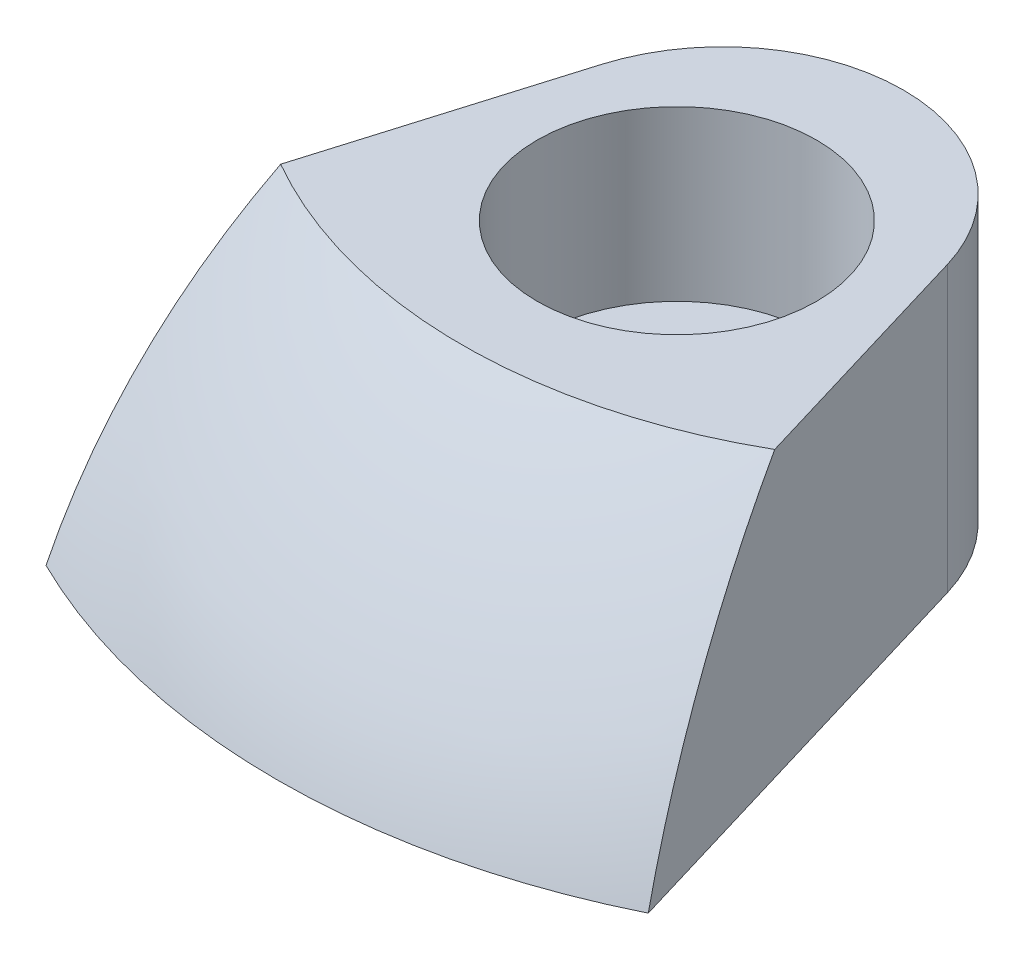
from build123d import *

# Parameters (mm, degrees)
CUT_EXTRUDE1_DEPTH = 8.493


with BuildPart() as part:
    # Sketch1 → Revolve1 (revolve)
    with BuildSketch(Plane.XY):
        with BuildLine():
            Line((0, 0), (19.05, 0))
            ThreePointArc((19.05, 0), (13.470384182, 13.470384182), (0, 19.05))
            Line((0, 19.05), (0, 0))
        make_face()
    revolve(axis=Axis((0, 19.05, 0), (0, -1, 0)))

    # SurfaceCut1
    split(bisect_by=Plane(origin=(0, 13.843, 0), x_dir=(-1, 0, 0), z_dir=(0, 1, 0)), keep=Keep.BOTTOM)

    # SurfaceCut2
    split(bisect_by=Plane(origin=(0, 6.35, 0), x_dir=(-1, 0, 0), z_dir=(0, 1, 0)), keep=Keep.TOP)

    # Sketch2 → Cut-Extrude1 (cut, through all)
    with BuildSketch(Plane(origin=(0, 6.35, 0), x_dir=(-1, 0, 0), z_dir=(0, 1, 0))):
        with BuildLine():
            Line((4.562115728, 4.846079058), (7.9375, 16.11136536))
            ThreePointArc((7.9375, 16.11136536), (0, -17.960512242), (-7.9375, 16.11136536))
            Line((-7.9375, 16.11136536), (-4.562115728, 4.846079058))
            ThreePointArc((-4.562115728, 4.846079058), (0, 1.450512242), (4.562115728, 4.846079058))
        make_face()
    extrude(amount=CUT_EXTRUDE1_DEPTH, mode=Mode.SUBTRACT)

    # Sketch4 → Cut-Revolve1 (revolve, cut)
    with BuildSketch(Plane(origin=(0, 0, 0), x_dir=(0, 0, -1), z_dir=(1, 0, 0))):
        Polygon((-7.419512242, 13.843), (-7.419512242, 6.35), (-5.197012242, 6.35), (-5.197012242, 9.398), (-3.736512242, 9.398), (-3.736512242, 13.843), align=None)
    revolve(axis=Axis((0, 6.35, 7.419512242), (0, 1, 0)), mode=Mode.SUBTRACT)


solid = part.part
